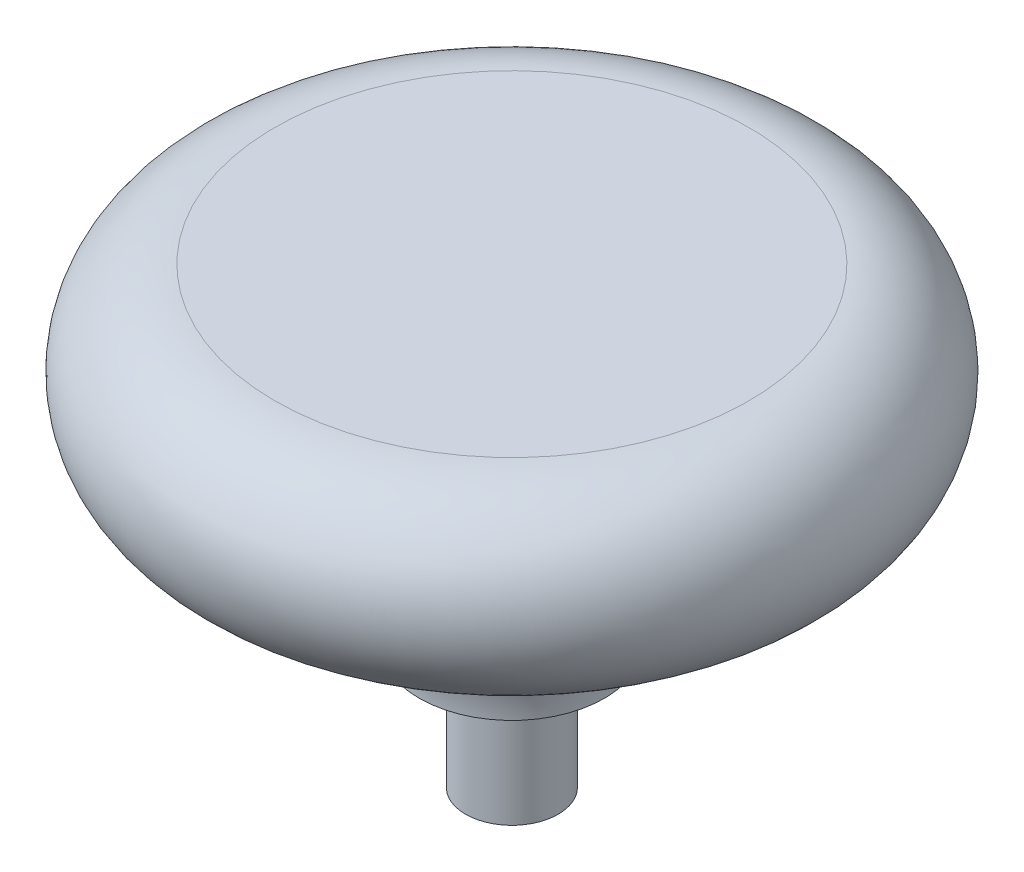
from build123d import *


with BuildPart() as part:
    # Sketch1 → Revolve1 (revolve)
    with BuildSketch(Plane.XY):
        with BuildLine():
            Line((0, 0), (2.25, 0))
            Line((2.25, 0), (2.25, 6))
            Line((2.25, 6), (4.5, 6))
            ThreePointArc((4.5, 6), (6.550252532, 10.949747468), (11.5, 13))
            ThreePointArc((11.5, 13), (16, 17.5), (11.5, 22))
            Line((11.5, 22), (0, 22))
            Line((0, 22), (0, 0))
        make_face()
    revolve(axis=Axis((0, 28.917241484, 0), (0, -1, 0)))


solid = part.part
